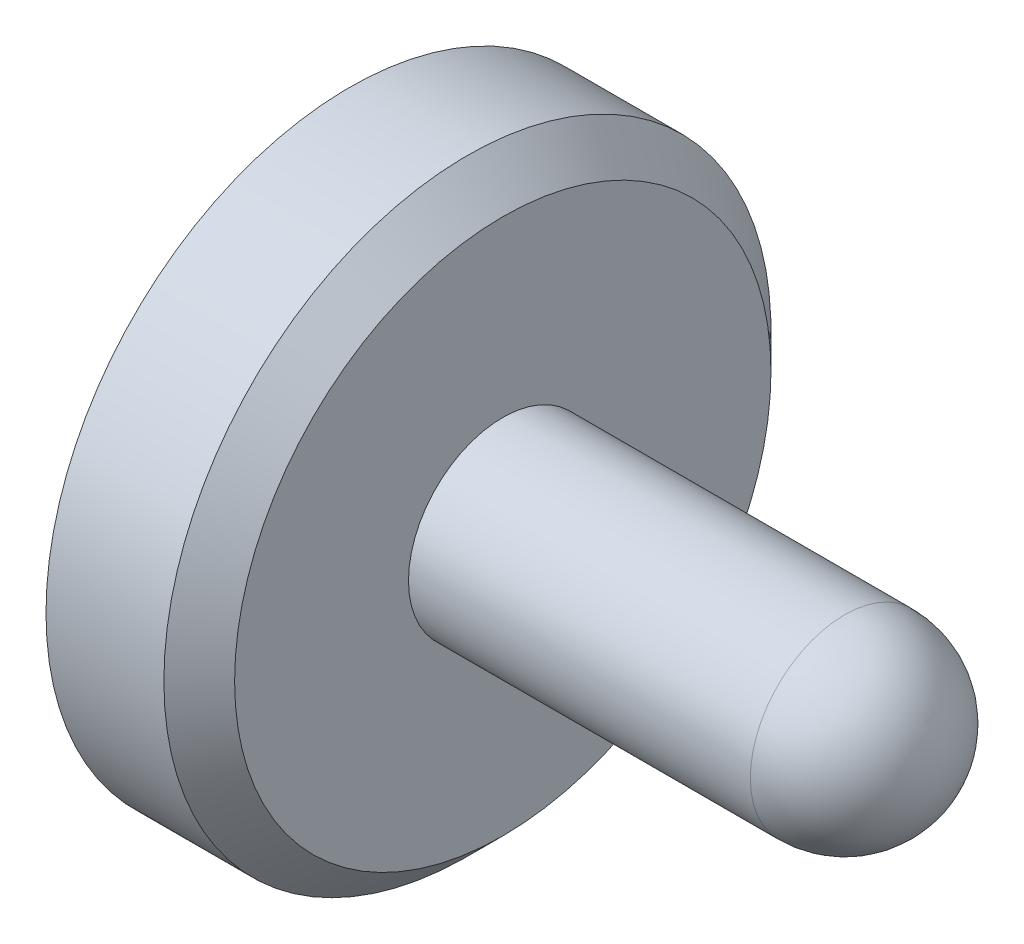
from build123d import *


with BuildPart() as part:
    # Sketch1 → RevolutionAngle1 (revolve)
    with BuildSketch(Plane.XY):
        with BuildLine():
            Line((0, 0), (0, 0.65405))
            Line((0, 0.65405), (0.254, 0.65405))
            Line((0.254, 0.65405), (0.3302, 0.57785))
            Line((0.3302, 0.57785), (0.3302, 0.2032))
            Line((0.3302, 0.2032), (1.0668, 0.2032))
            ThreePointArc((1.0668, 0.2032), (1.210484098, 0.143684098), (1.27, 0))
            Line((1.27, 0), (0, 0))
        make_face()
    revolve(axis=Axis((0, 0, 0), (1, 0, 0)))


solid = part.part
